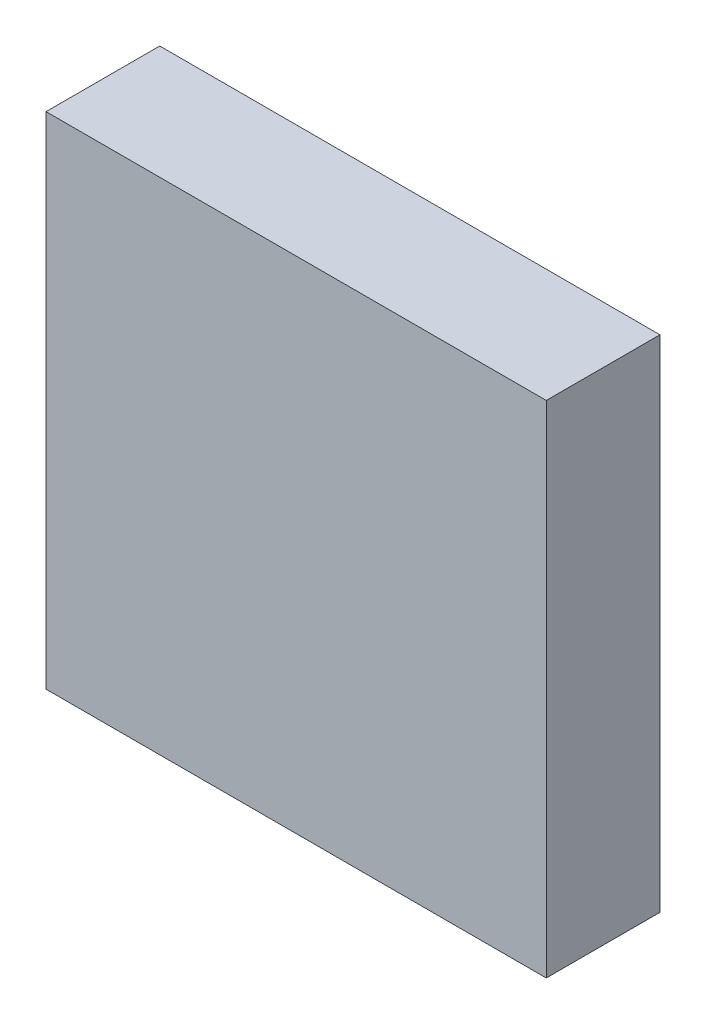
from build123d import *

# Parameters (mm, degrees)
SKETCH1_W           = 11
SKETCH1_H           = 11
BOSS_EXTRUDE1_DEPTH = 1.25


with BuildPart() as part:
    # Sketch1 → Boss-Extrude1 (new body, symmetric)
    with BuildSketch(Plane.XY):
        Rectangle(SKETCH1_W, SKETCH1_H)
    extrude(amount=BOSS_EXTRUDE1_DEPTH, both=True)


solid = part.part
